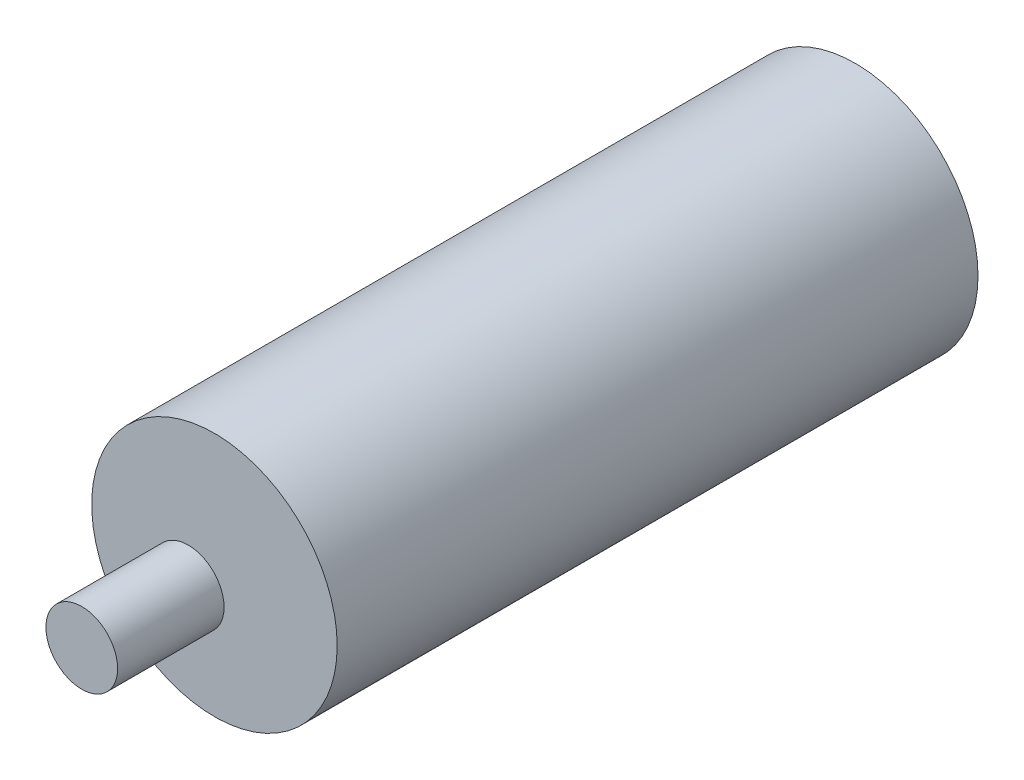
from build123d import *

# Parameters (mm, degrees)
SKETCH2_R           = 28.702
BOSS_EXTRUDE1_DEPTH = 149.86
SKETCH3_R           = 8.382
BOSS_EXTRUDE2_DEPTH = 24.892


with BuildPart() as part:
    # Sketch2 → Boss-Extrude1 (new body)
    with BuildSketch(Plane.XY):
        Circle(SKETCH2_R)
    extrude(amount=BOSS_EXTRUDE1_DEPTH)

    # Sketch3 → Boss-Extrude2 (add)
    with BuildSketch(Plane.XY.offset(149.86)):
        with Locations((-6.132072716, -5.385454815)):
            Circle(SKETCH3_R)
    extrude(amount=BOSS_EXTRUDE2_DEPTH)


solid = part.part
